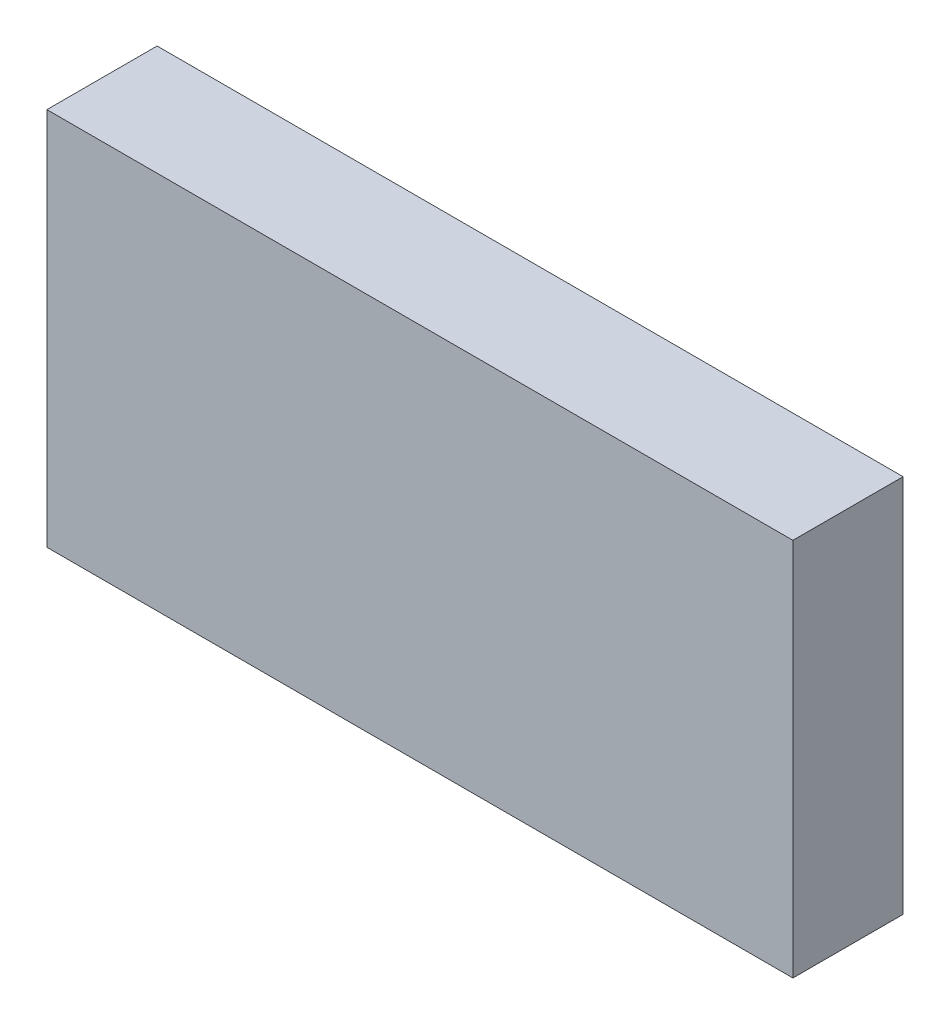
from build123d import *

# Parameters (mm, degrees)
BOSS_EXTRUDE1_DEPTH      = 172
BOSS_EXTRUDE1_DEPTH_BACK = 172
SKETCH2_W                = 677
SKETCH2_H                = 100


with BuildPart() as part:
    # Sketch2 → Boss-Extrude1 (new, two sides: drawn at the far end of the back side and taken through both)
    with BuildSketch(Plane(origin=(0, 0, 0), x_dir=(1, 0, 0), z_dir=(0, 1, 0)).offset(-BOSS_EXTRUDE1_DEPTH_BACK)):
        Rectangle(SKETCH2_W, SKETCH2_H)
    extrude(amount=BOSS_EXTRUDE1_DEPTH + BOSS_EXTRUDE1_DEPTH_BACK)


solid = part.part
